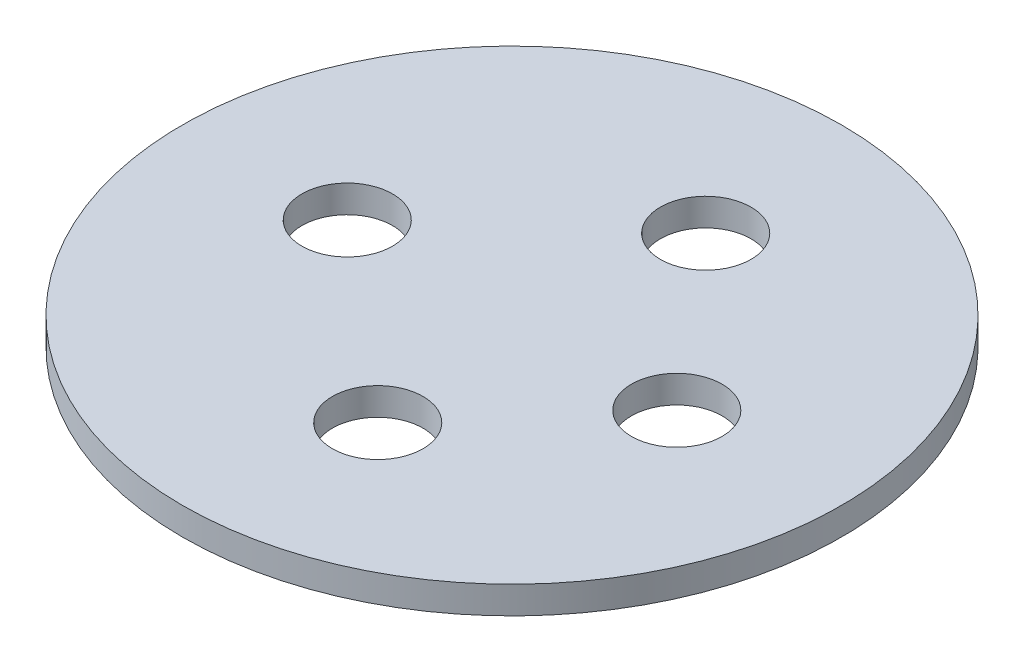
from build123d import *

# Parameters (mm, degrees)
SKETCH1_R           = 12
BOSS_EXTRUDE1_DEPTH = 1
SKETCH1_3_R         = 1.65
CUT_EXTRUDE1_DEPTH  = 1


with BuildPart() as part:
    # Sketch1 → Boss-Extrude1 (new body)
    with BuildSketch(Plane(origin=(0, 0, 0), x_dir=(1, 0, 0), z_dir=(0, 1, 0))):
        with Locations((-1.34521469, 0.946943509)):
            Circle(SKETCH1_R)
    extrude(amount=-BOSS_EXTRUDE1_DEPTH)

    # Sketch1_3 → Cut-Extrude1 (cut)
    with BuildSketch(Plane(origin=(0, 0, 0), x_dir=(1, 0, 0), z_dir=(0, 1, 0))):
        with Locations((-0.402320715, 7.056431016)):
            Circle(SKETCH1_3_R)
        with Locations((-0.402320715, -4.885610672)):
            Circle(SKETCH1_3_R)
        with Locations((-7.34521469, 0.946943509)):
            Circle(SKETCH1_3_R)
        with Locations((4.65478531, 0.946943509)):
            Circle(SKETCH1_3_R)
    extrude(amount=-CUT_EXTRUDE1_DEPTH, mode=Mode.SUBTRACT)


solid = part.part
